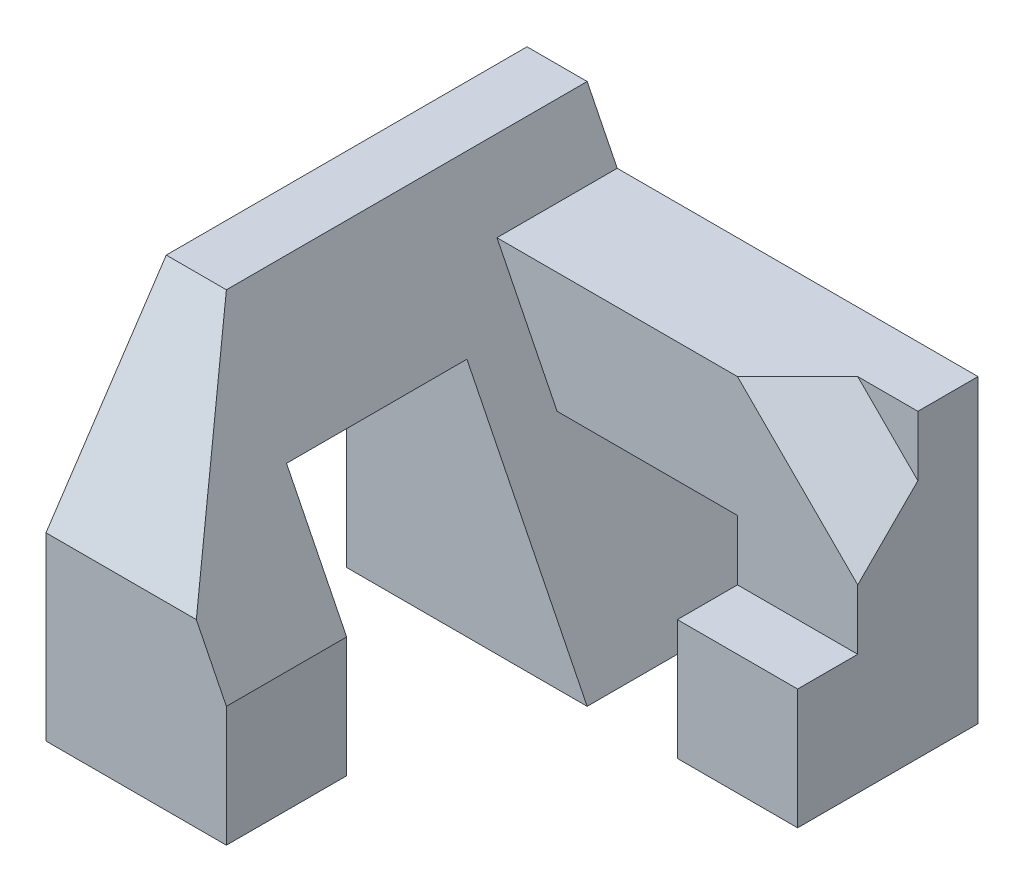
from build123d import *

# Parameters (mm, degrees)
SKETCH1_W           = 4
SKETCH1_H           = 6
BOSS_EXTRUDE1_DEPTH = 8
SKETCH6_W           = 8
SKETCH6_H           = 6.708203932
CUT_EXTRUDE4_DEPTH  = 8
SKETCH7_W           = 3
SKETCH7_H           = 3
CUT_EXTRUDE5_DEPTH  = 10.433981132
SKETCH8_W           = 1
SKETCH8_H           = 2
CUT_EXTRUDE6_DEPTH  = 11.198039027
SKETCH9_W           = 3
SKETCH9_H           = 1
CUT_EXTRUDE7_DEPTH  = 10.433981132
CUT_EXTRUDE8_DEPTH  = 10.433981132
SKETCH12_W          = 2
SKETCH12_H          = 2
BOSS_EXTRUDE2_DEPTH = 3
SKETCH13_W          = 2
SKETCH13_H          = 2
BOSS_EXTRUDE3_DEPTH = 1.5
SKETCH14_W          = 2
SKETCH14_H          = 2
BOSS_EXTRUDE4_DEPTH = 3
SKETCH15_W          = 2
SKETCH15_H          = 2
BOSS_EXTRUDE5_DEPTH = 1
CUT_EXTRUDE9_DEPTH  = 1
CUT_EXTRUDE10_DEPTH = 1


with BuildPart() as part:
    # Sketch1 → Boss-Extrude1 (new body)
    with BuildSketch(Plane.XY):
        Rectangle(SKETCH1_W, SKETCH1_H)
    extrude(amount=BOSS_EXTRUDE1_DEPTH)

    # Sketch6 → Cut-Extrude4 (cut)
    with BuildSketch(Plane(origin=(0.4, 0.2, 0), x_dir=(0, 0, -1), z_dir=(0.894427190999916, 0.4472135954999579, 0))):
        with Locations((-4, -0.223606798)):
            Rectangle(SKETCH6_W, SKETCH6_H)
    extrude(amount=CUT_EXTRUDE4_DEPTH, mode=Mode.SUBTRACT)

    # Sketch7 → Cut-Extrude5 (cut, through all)
    with BuildSketch(Plane.ZY.offset(2)):
        with Locations((4.5, -1.5)):
            Rectangle(SKETCH7_W, SKETCH7_H)
    extrude(amount=-CUT_EXTRUDE5_DEPTH, mode=Mode.SUBTRACT)

    # Sketch8 → Cut-Extrude6 (cut, through all)
    with BuildSketch(Plane.XZ.offset(3)):
        with Locations((1.5, 7)):
            Rectangle(SKETCH8_W, SKETCH8_H)
    extrude(amount=-CUT_EXTRUDE6_DEPTH, mode=Mode.SUBTRACT)

    # Sketch9 → Cut-Extrude7 (cut, through all)
    with BuildSketch(Plane.ZY.offset(2)):
        with Locations((4.5, 0.5)):
            Rectangle(SKETCH9_W, SKETCH9_H)
    extrude(amount=-CUT_EXTRUDE7_DEPTH, mode=Mode.SUBTRACT)

    # Sketch10 → Cut-Extrude8 (cut, through all)
    with BuildSketch(Plane.ZY.offset(2)):
        Polygon((6, 3), (8, 0), (8, 3), align=None)
    extrude(amount=-CUT_EXTRUDE8_DEPTH, mode=Mode.SUBTRACT)

    # Sketch12 → Boss-Extrude2 (add, symmetric)
    with BuildSketch(Plane(origin=(1, 0, 0), x_dir=(0, 0, -1), z_dir=(1, 0, 0))):
        with Locations((-1, 1)):
            Rectangle(SKETCH12_W, SKETCH12_H)
    extrude(amount=BOSS_EXTRUDE2_DEPTH, both=True)

    # Sketch13 → Boss-Extrude3 (add)
    with BuildSketch(Plane(origin=(4, 0, 0), x_dir=(0, 0, -1), z_dir=(1, 0, 0))):
        with Locations((-1, 1)):
            Rectangle(SKETCH13_W, SKETCH13_H)
    extrude(amount=BOSS_EXTRUDE3_DEPTH)

    # Sketch14 → Boss-Extrude4 (add)
    with BuildSketch(Plane.XZ):
        with Locations((4.5, 1)):
            Rectangle(SKETCH14_W, SKETCH14_H)
    extrude(amount=BOSS_EXTRUDE4_DEPTH)

    # Sketch15 → Boss-Extrude5 (add)
    with BuildSketch(Plane.XY.offset(2)):
        with Locations((4.5, -2)):
            Rectangle(SKETCH15_W, SKETCH15_H)
    extrude(amount=BOSS_EXTRUDE5_DEPTH)

    # Sketch18 → Cut-Extrude9 (cut)
    with BuildSketch(Plane.XY.offset(2)):
        Polygon((5.5, 1), (4.5, 2), (5.5, 2), align=None)
    extrude(amount=-CUT_EXTRUDE9_DEPTH, mode=Mode.SUBTRACT)

    # 3DSketch1 → Cut-Extrude10 (cut, along a direction that is not the sketch's normal)
    with BuildSketch(Plane(origin=(5.5, 0, 2), x_dir=(-0.7071067811865472, 0.707106781186548, 0), z_dir=(-0.577350269189626, -0.5773502691896253, -0.5773502691896261))):
        Polygon((0, 0), (0.707106781, 1.224744871), (2.121320344, 1.224744871), (2.828427125, 0), align=None)
    extrude(amount=-CUT_EXTRUDE10_DEPTH, dir=(-0.7071067811865478, -0.7071067811865472, 0), mode=Mode.SUBTRACT)


solid = part.part
